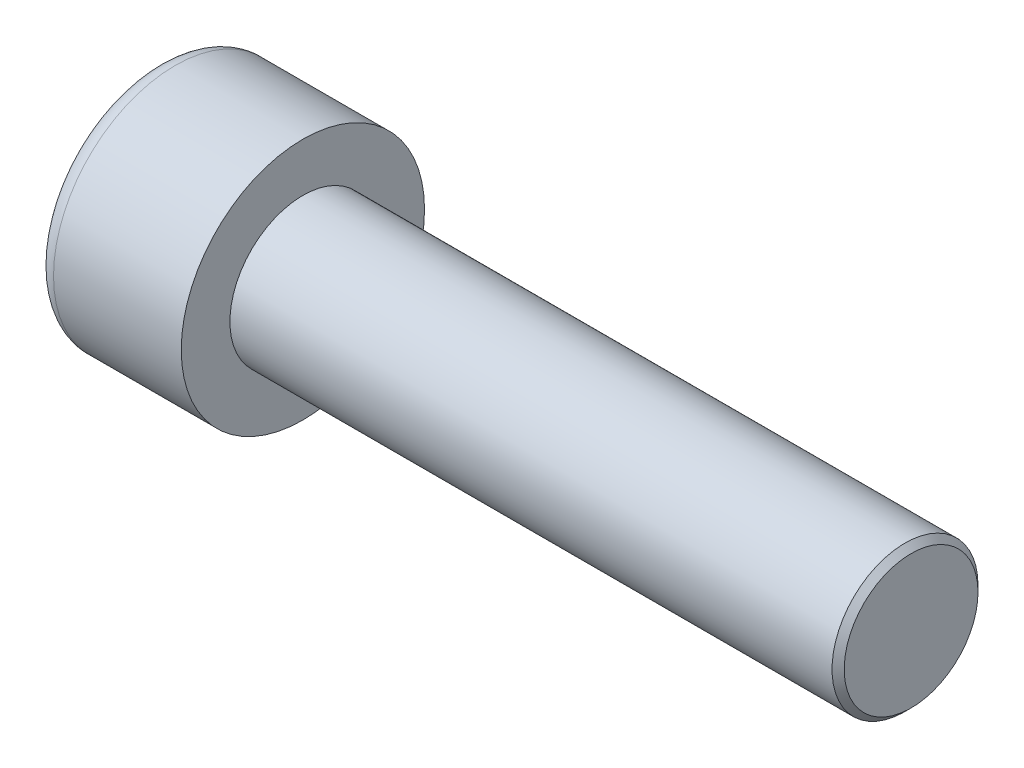
from build123d import *

# Parameters (mm, degrees)
SKETCH1_R           = 5
BASEHEAD_DEPTH      = 6
SKETCH2_R           = 3
BASEBODY_DEPTH      = 25
HEXAGONSOCKET_DEPTH = 3
TOPFILLET_R         = 0.75
CHAMFER1_SIZE       = 0.25


with BuildPart() as part:
    # Sketch1 → BaseHead (new body)
    with BuildSketch(Plane(origin=(0, 0, 0), x_dir=(0, 0, -1), z_dir=(1, 0, 0))):
        Circle(SKETCH1_R)
    extrude(amount=BASEHEAD_DEPTH)

    # Sketch2 → BaseBody (add)
    with BuildSketch(Plane(origin=(6, 0, 0), x_dir=(0, 0, -1), z_dir=(1, 0, 0))):
        Circle(SKETCH2_R)
    extrude(amount=BASEBODY_DEPTH)

    # Sketch3 → HexagonSocket (cut)
    with BuildSketch(Plane(origin=(0, 0, 0), x_dir=(0, 0, -1), z_dir=(1, 0, 0))):
        Polygon((2.886751346, 0), (1.443375673, 2.5), (-1.443375673, 2.5), (-2.886751346, 0), (-1.443375673, -2.5), (1.443375673, -2.5), align=None)
    extrude(amount=HEXAGONSOCKET_DEPTH, mode=Mode.SUBTRACT)

    # Sketch4 → Cut-Revolve1 (revolve, cut)
    with BuildSketch(Plane(origin=(-4.19613823, 0.75, 0), x_dir=(-1, 0, 0), z_dir=(0, 0, 1))):
        Polygon((-7.19613823, 3.25), (-8.639513903, 0.75), (-7.19613823, 0.75), align=None)
    revolve(axis=Axis((0.838992387, 0, 0), (-1, 0, 0)), mode=Mode.SUBTRACT)

    # TopFillet
    topfillet_edges = [part.edges().sort_by_distance(p)[0] for p in [
        (0, 0, 5),
    ]]
    fillet(topfillet_edges, radius=TOPFILLET_R)

    # Chamfer1
    chamfer1_edges = [part.edges().sort_by_distance(p)[0] for p in [
        (31, 0, 3),
    ]]
    chamfer(chamfer1_edges, length=CHAMFER1_SIZE)


solid = part.part
